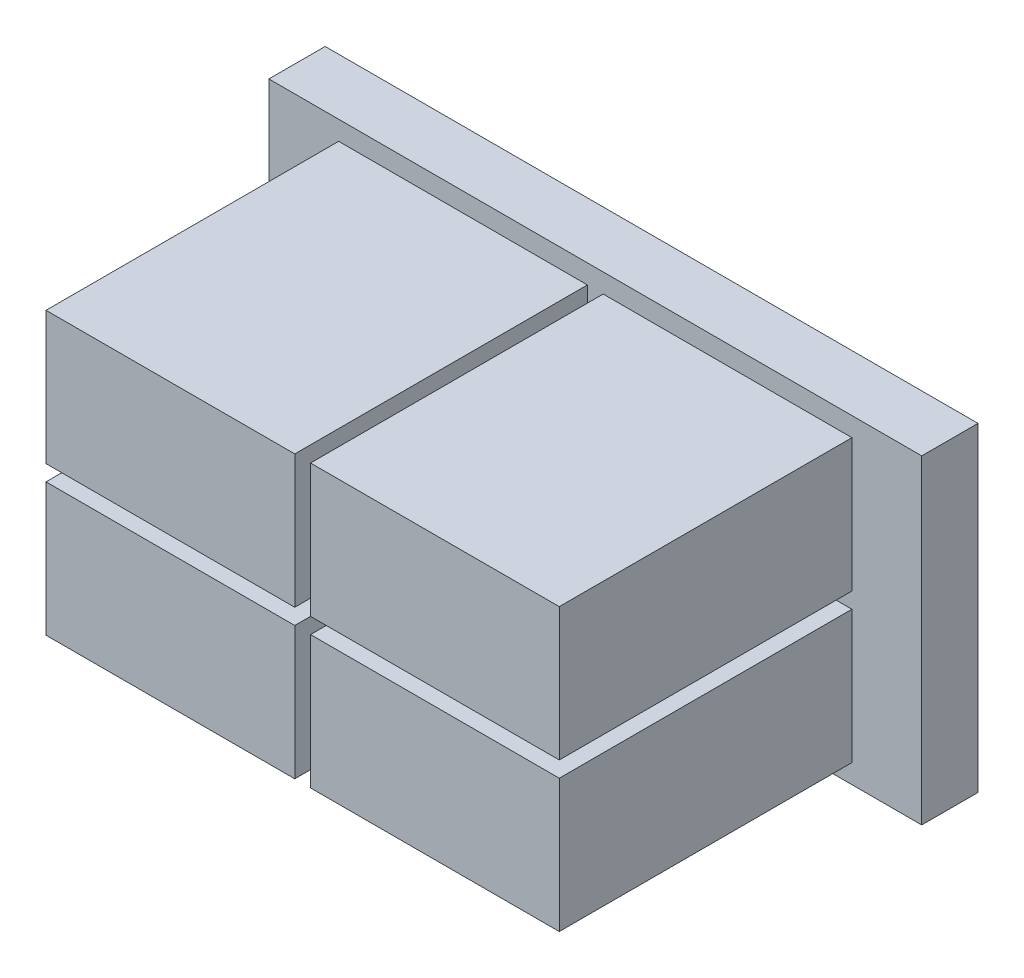
from build123d import *

# Parameters (mm, degrees)
CROQUIS1_W              = 29
CROQUIS1_H              = 14.2
SALIENTE_EXTRUIR1_DEPTH = 2.5
CROQUIS3_W              = 11.05
CROQUIS3_H              = 5.9
SALIENTE_EXTRUIR2_DEPTH = 13


with BuildPart() as part:
    # Croquis1 → Saliente-Extruir1 (new body)
    with BuildSketch(Plane.XY):
        Rectangle(CROQUIS1_W, CROQUIS1_H)
    extrude(amount=SALIENTE_EXTRUIR1_DEPTH)

    # Croquis3 → Saliente-Extruir2 (add)
    with BuildSketch(Plane.XY.offset(2.5)):
        with Locations((-5.875, 3.3)):
            Rectangle(CROQUIS3_W, CROQUIS3_H)
        with Locations((-5.875, -3.3)):
            Rectangle(CROQUIS3_W, CROQUIS3_H)
        with Locations((5.875, 3.3)):
            Rectangle(CROQUIS3_W, CROQUIS3_H)
        with Locations((5.875, -3.3)):
            Rectangle(CROQUIS3_W, CROQUIS3_H)
    extrude(amount=SALIENTE_EXTRUIR2_DEPTH)


solid = part.part
